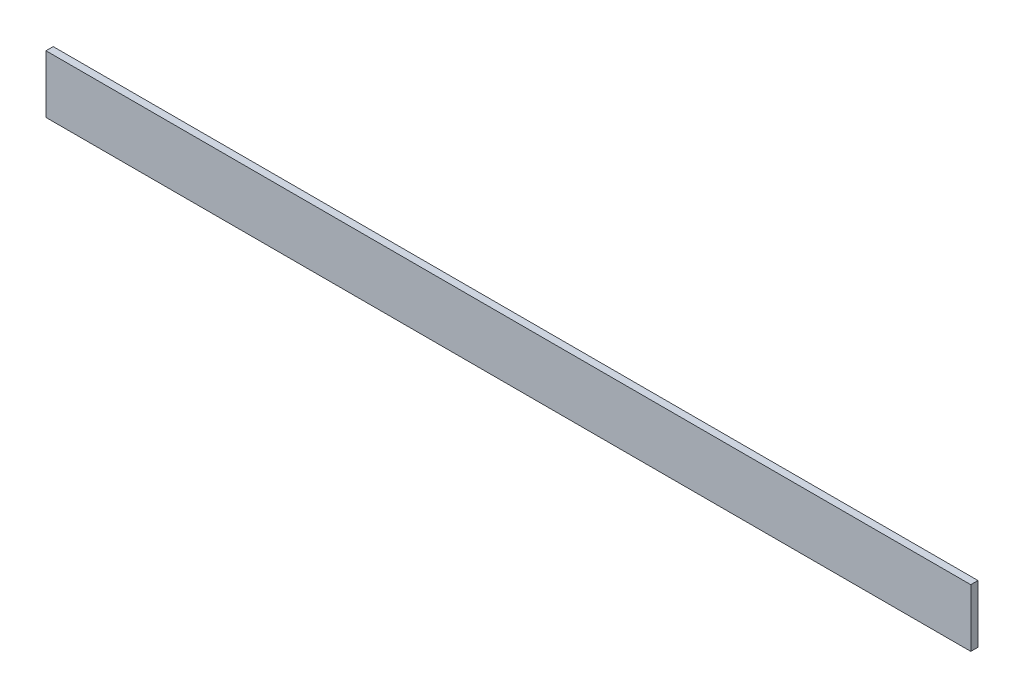
from build123d import *

# Parameters (mm, degrees)
ESQUISSE1_W        = 640
ESQUISSE1_H        = 40
BOSS_EXTRU_1_DEPTH = 5


with BuildPart() as part:
    # Esquisse1 → Boss.-Extru.1 (new body)
    with BuildSketch(Plane.XY):
        Rectangle(ESQUISSE1_W, ESQUISSE1_H)
    extrude(amount=BOSS_EXTRU_1_DEPTH)


solid = part.part
